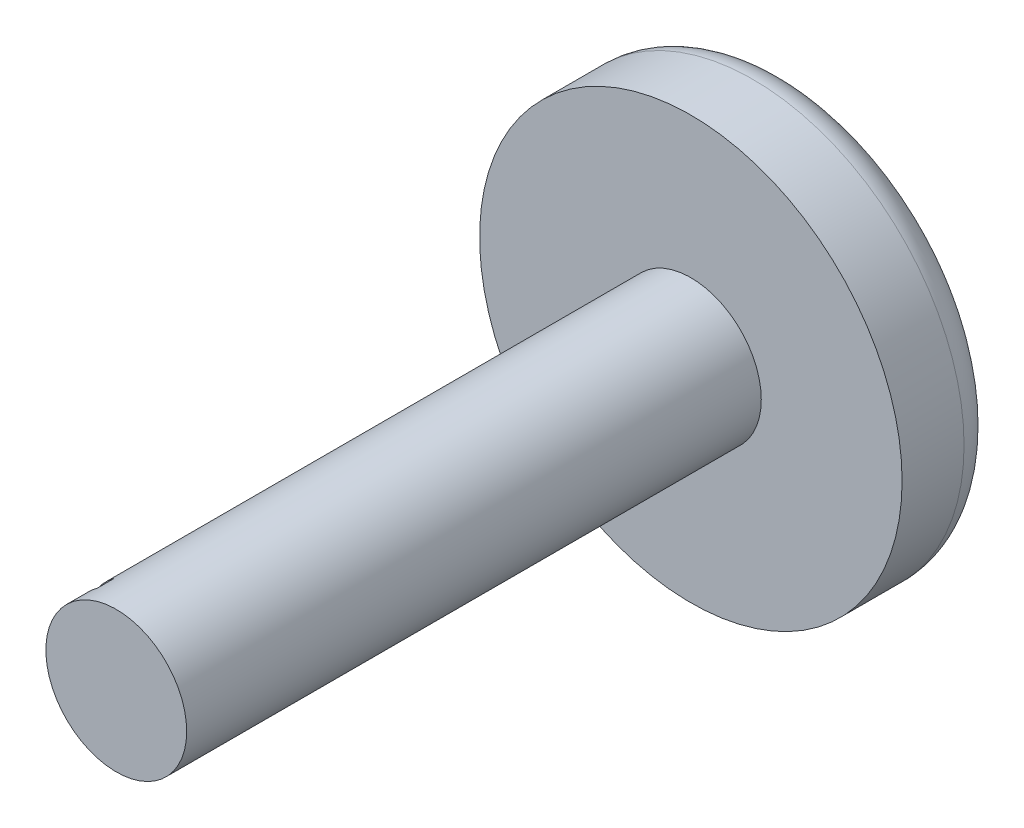
from build123d import *

# Parameters (mm, degrees)
SKETCH1_R           = 3.75
BOSS_EXTRUDE1_DEPTH = 11.9
SKETCH2_R           = 3.75
SKETCH2_R_2         = 1.25
CUT_EXTRUDE1_DEPTH  = 10.2
FILLET1_R           = 0.6
CUT_EXTRUDE2_DEPTH  = 0.3


with BuildPart() as part:
    # Sketch1 → Boss-Extrude1 (new body)
    with BuildSketch(Plane.XY):
        Circle(SKETCH1_R)
    extrude(amount=BOSS_EXTRUDE1_DEPTH)

    # Sketch2 → Cut-Extrude1 (cut)
    with BuildSketch(Plane.XY.offset(11.9)):
        Circle(SKETCH2_R)
        Circle(SKETCH2_R_2, mode=Mode.SUBTRACT)
    extrude(amount=-CUT_EXTRUDE1_DEPTH, mode=Mode.SUBTRACT)

    # Fillet1
    fillet1_edges = [part.edges().sort_by_distance(p)[0] for p in [
        (-3.75, 0, 0),
    ]]
    fillet(fillet1_edges, radius=FILLET1_R)

    # Sketch3 → Cut-Extrude2 (cut)
    with BuildSketch(Plane.XY.offset(11.5)):
        with BuildLine():
            Line((0, 0.466411964), (-0.73212486, 1.013160002))
            ThreePointArc((-0.73212486, 1.013160002), (-1.25, 0), (-0.73212486, -1.013160002))
            Line((-0.73212486, -1.013160002), (0, -0.466411964))
            Line((0, -0.466411964), (0, 0.466411964))
        make_face()
    extrude(amount=-CUT_EXTRUDE2_DEPTH, mode=Mode.SUBTRACT)


solid = part.part
